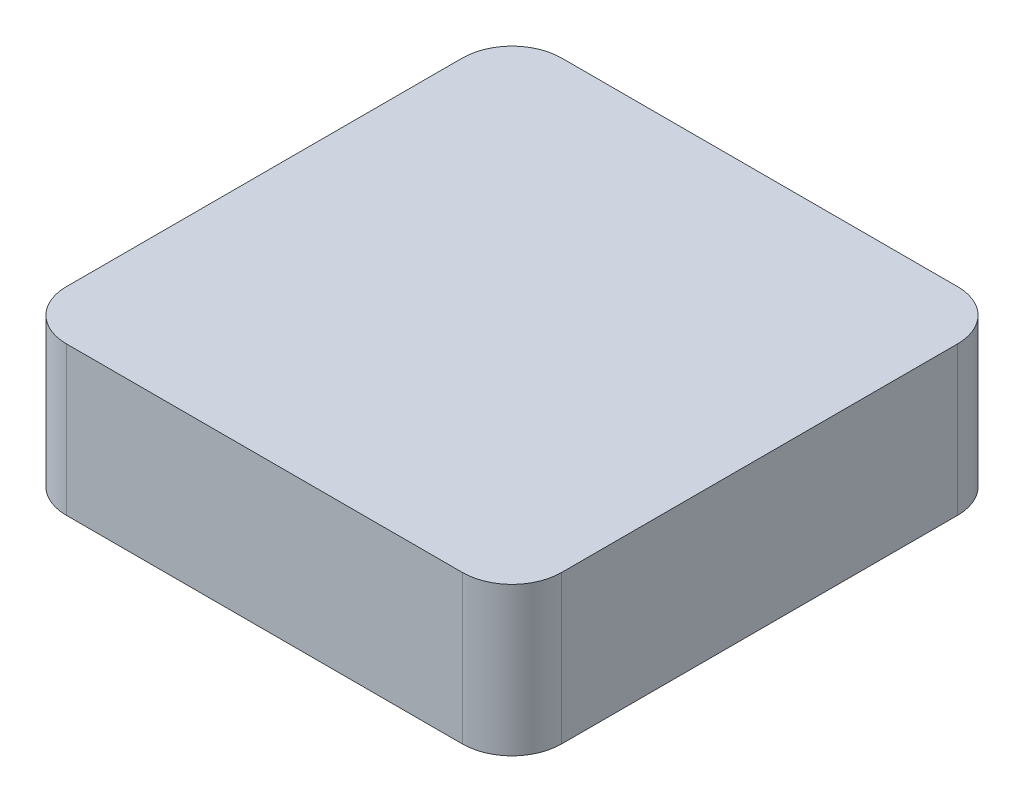
from build123d import *

# Parameters (mm, degrees)
BOSS_EXTRUDE1_DEPTH = 38.1


with BuildPart() as part:
    # Sketch1 → Boss-Extrude1 (new body)
    with BuildSketch(Plane(origin=(0, 0, 0), x_dir=(1, 0, 0), z_dir=(0, 1, 0))):
        with BuildLine():
            Line((-50.8, -63.5), (50.8, -63.5))
            ThreePointArc((50.8, -63.5), (59.780256121, -59.780256121), (63.5, -50.8))
            Line((63.5, -50.8), (63.5, 50.8))
            ThreePointArc((63.5, 50.8), (59.780256121, 59.780256121), (50.8, 63.5))
            Line((50.8, 63.5), (-50.8, 63.5))
            ThreePointArc((-50.8, 63.5), (-59.780256121, 59.780256121), (-63.5, 50.8))
            Line((-63.5, 50.8), (-63.5, -50.8))
            ThreePointArc((-63.5, -50.8), (-59.780256121, -59.780256121), (-50.8, -63.5))
        make_face()
    extrude(amount=BOSS_EXTRUDE1_DEPTH)


solid = part.part
